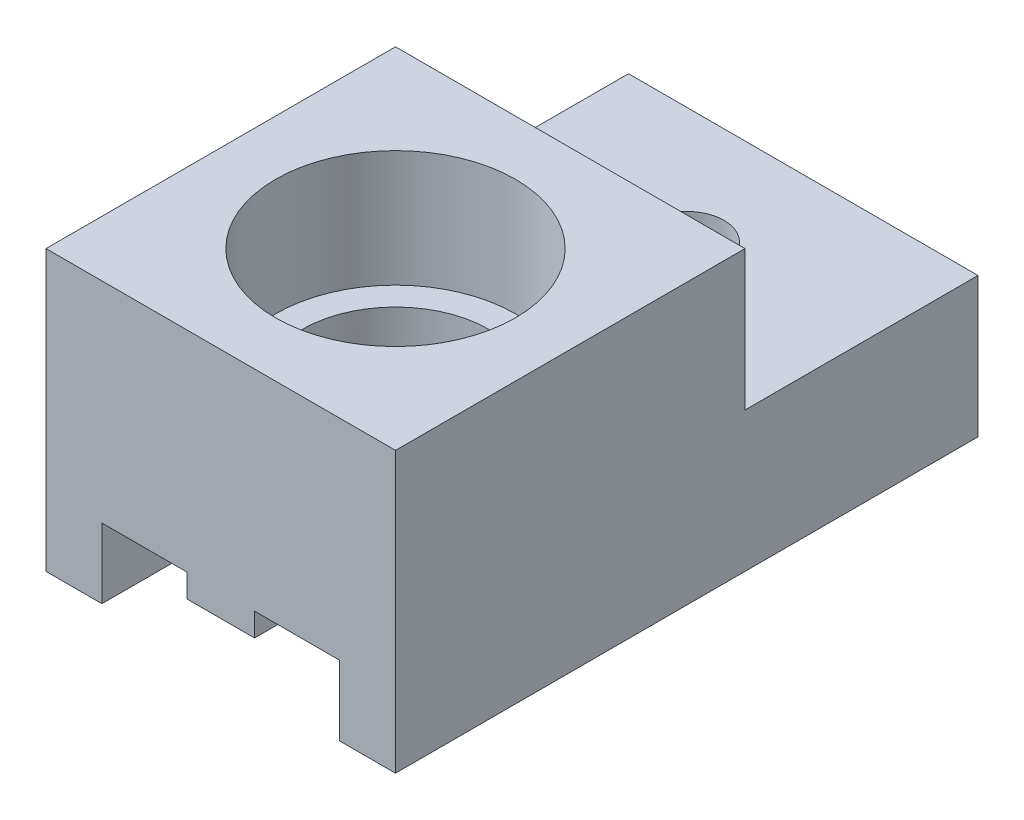
from build123d import *

# Parameters (mm, degrees)
MAIN_DEPTH         = 25
SKETCH2_R          = 5.15
ROLLINGHOLE_DEPTH  = 5
SKETCH3_R          = 4
CUT_EXTRUDE2_DEPTH = 8
SKETCH4_R          = 1.6
FIXHOLE_DEPTH      = 13
SKETCH5_W          = 10
SKETCH5_H          = 6
CUT_EXTRUDE4_DEPTH = 16


with BuildPart() as part:
    # Sketch1 → Main (new body)
    with BuildSketch(Plane.XY):
        Polygon((-5.1, 0), (-5.1, -3), (-7.5, -3), (-7.5, 9), (7.5, 9), (7.5, -3), (5.1, -3), (5.1, 0), (1.45, 0), (1.45, -1), (-1.45, -1), (-1.45, 0), align=None)
    extrude(amount=MAIN_DEPTH)

    # Sketch2 → RollingHole (cut)
    with BuildSketch(Plane(origin=(0, 9, 0), x_dir=(1, 0, 0), z_dir=(0, 1, 0))):
        with Locations((0, -17.5)):
            Circle(SKETCH2_R)
    extrude(amount=-ROLLINGHOLE_DEPTH, mode=Mode.SUBTRACT)

    # Sketch3 → Cut-Extrude2 (cut, through all)
    with BuildSketch(Plane(origin=(0, 4, 0), x_dir=(1, 0, 0), z_dir=(0, 1, 0))):
        with Locations((0, -17.5)):
            Circle(SKETCH3_R)
    extrude(amount=-CUT_EXTRUDE2_DEPTH, mode=Mode.SUBTRACT)

    # Sketch4 → FixHole (cut, through all)
    with BuildSketch(Plane(origin=(0, 9, 0), x_dir=(1, 0, 0), z_dir=(0, 1, 0))):
        with Locations((0, -5)):
            Circle(SKETCH4_R)
    extrude(amount=-FIXHOLE_DEPTH, mode=Mode.SUBTRACT)

    # Sketch5 → Cut-Extrude4 (cut, through all)
    with BuildSketch(Plane.ZY.offset(7.5)):
        with Locations((5, 6)):
            Rectangle(SKETCH5_W, SKETCH5_H)
    extrude(amount=-CUT_EXTRUDE4_DEPTH, mode=Mode.SUBTRACT)


solid = part.part
